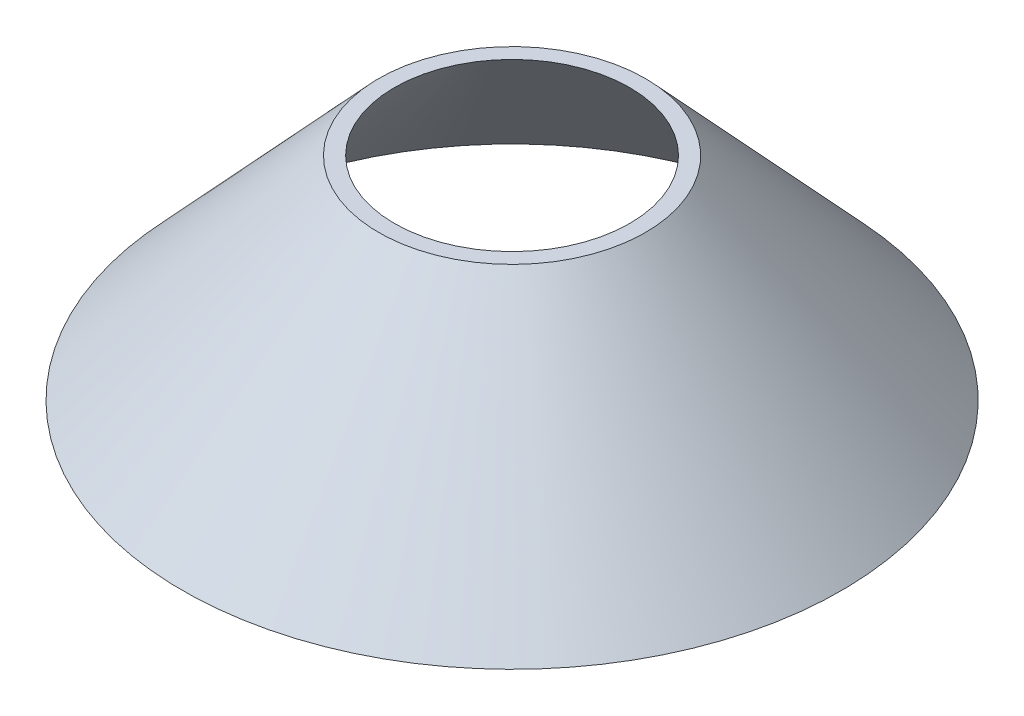
from build123d import *


with BuildPart() as part:
    # Sketch1 → Revolve1 (revolve)
    with BuildSketch(Plane.XY):
        Polygon((53.34, 0), (50.8, 0), (19.05, 34.304431818), (21.59, 34.304431818), (25.4, 30.1879), align=None)
    revolve(axis=Axis((0, 0, 0), (0, 1, 0)))


solid = part.part
